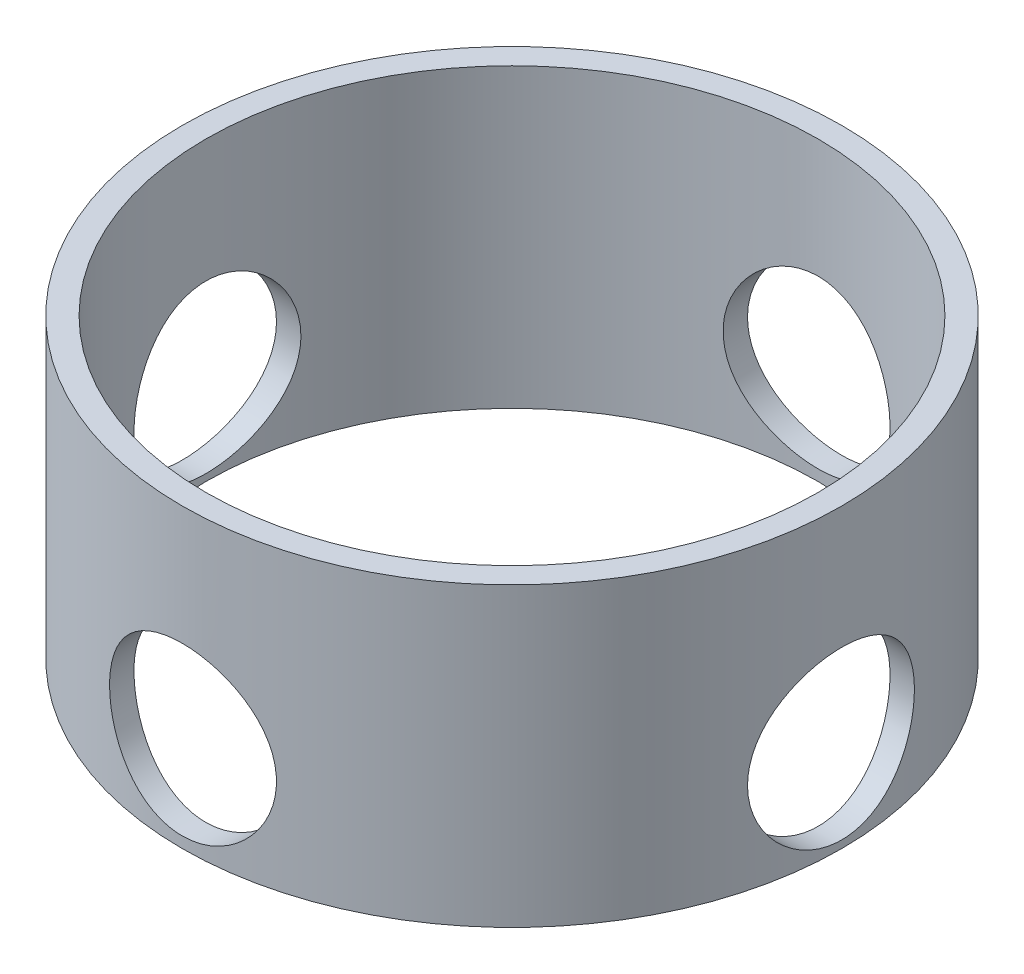
from build123d import *

# Parameters (mm, degrees)
SKETCH1_R           = 88.9
BOSS_EXTRUDE1_DEPTH = 80
SKETCH2_R           = 82.55
CUT_EXTRUDE4_DEPTH  = 90
SKETCH12_R          = 22.5
CUT_EXTRUDE5_DEPTH  = 115.64
SKETCH13_R          = 22.5
CUT_EXTRUDE6_DEPTH  = 115.64
SKETCH14_R          = 22.5
CUT_EXTRUDE7_DEPTH  = 99.64
CUT_EXTRUDE8_START  = 137.64
SKETCH15_R          = 22.5
CUT_EXTRUDE8_DEPTH  = 137.64


with BuildPart() as part:
    # Sketch1 → Boss-Extrude1 (new body)
    with BuildSketch(Plane(origin=(0, 0, 0), x_dir=(1, 0, 0), z_dir=(0, 1, 0))):
        Circle(SKETCH1_R)
    extrude(amount=BOSS_EXTRUDE1_DEPTH)

    # Sketch2 → Cut-Extrude4 (cut)
    with BuildSketch(Plane(origin=(0, 0, 0), x_dir=(1, 0, 0), z_dir=(0, 1, 0))):
        Circle(SKETCH2_R)
    extrude(amount=CUT_EXTRUDE4_DEPTH, mode=Mode.SUBTRACT)

    # Sketch12 → Cut-Extrude5 (cut)
    with BuildSketch(Plane(origin=(0, 0, 0), x_dir=(0, 0, -1), z_dir=(1, 0, 0))):
        with Locations((0, 24.336091646)):
            Circle(SKETCH12_R)
    extrude(amount=-CUT_EXTRUDE5_DEPTH, mode=Mode.SUBTRACT)

    # Sketch13 → Cut-Extrude6 (cut)
    with BuildSketch(Plane.XY):
        with Locations((0, 25.450721797)):
            Circle(SKETCH13_R)
    extrude(amount=-CUT_EXTRUDE6_DEPTH, mode=Mode.SUBTRACT)

    # Sketch14 → Cut-Extrude7 (cut)
    with BuildSketch(Plane(origin=(0, 0, 0), x_dir=(0, 0, -1), z_dir=(1, 0, 0))):
        with Locations((0, 24.521863338)):
            Circle(SKETCH14_R)
    extrude(amount=CUT_EXTRUDE7_DEPTH, mode=Mode.SUBTRACT)

    # Sketch15 → Cut-Extrude8 (cut)
    with BuildSketch(Plane.XY.offset(CUT_EXTRUDE8_START)):
        with Locations((0, 25.450721797)):
            Circle(SKETCH15_R)
    extrude(amount=-CUT_EXTRUDE8_DEPTH, mode=Mode.SUBTRACT)


solid = part.part
